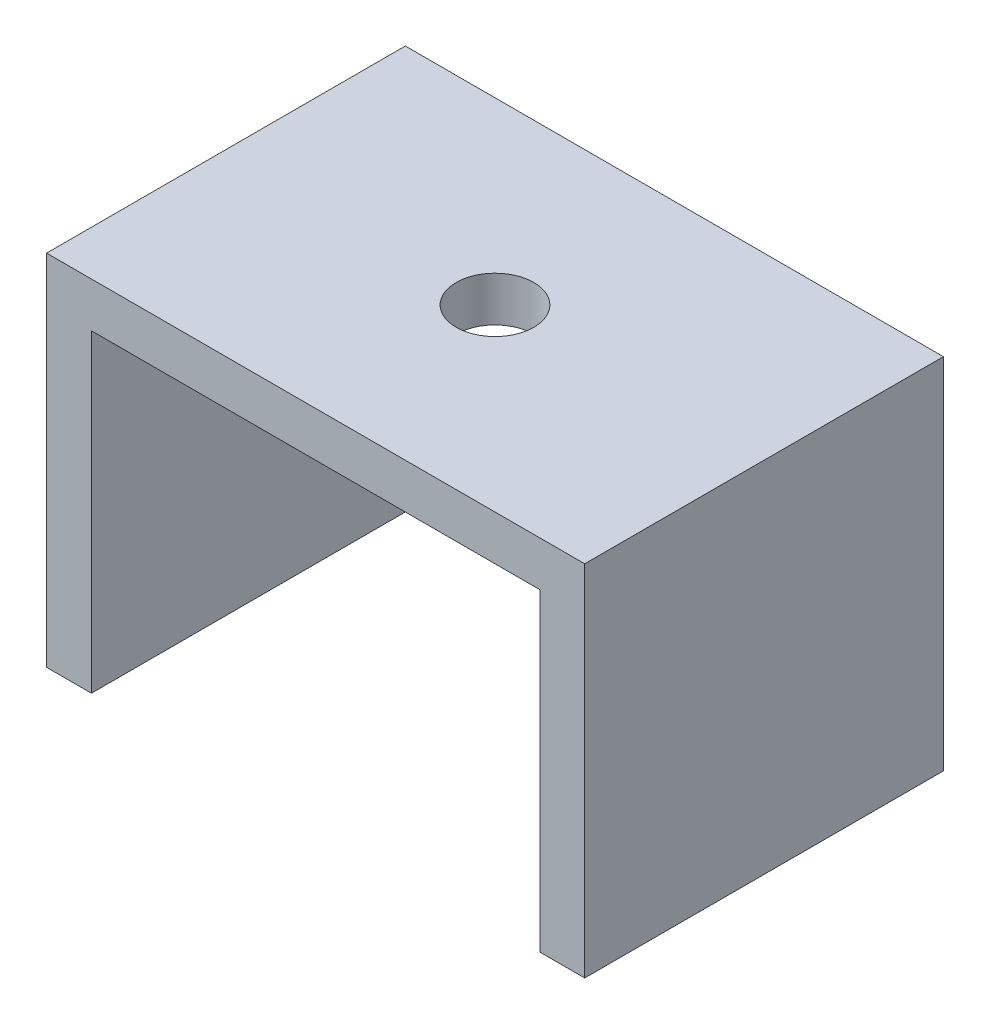
from build123d import *

# Parameters (mm, degrees)
BOSS_EXTRUDE1_DEPTH = 50.8
SKETCH2_R           = 5.5
CUT_EXTRUDE1_DEPTH  = 50.8


with BuildPart() as part:
    # Sketch1 → Boss-Extrude1 (new body)
    with BuildSketch(Plane.XY):
        Polygon((38.1, 6.35), (-38.1, 6.35), (-38.1, -44.45), (-31.75, -44.45), (-31.75, 0), (31.75, 0), (31.75, -44.45), (38.1, -44.45), align=None)
    extrude(amount=BOSS_EXTRUDE1_DEPTH)

    # Sketch2 → Cut-Extrude1 (cut)
    with BuildSketch(Plane(origin=(0, 6.35, 0), x_dir=(1, 0, 0), z_dir=(0, 1, 0))):
        with Locations((0, -25.4)):
            Circle(SKETCH2_R)
    extrude(amount=-CUT_EXTRUDE1_DEPTH, mode=Mode.SUBTRACT)


solid = part.part
